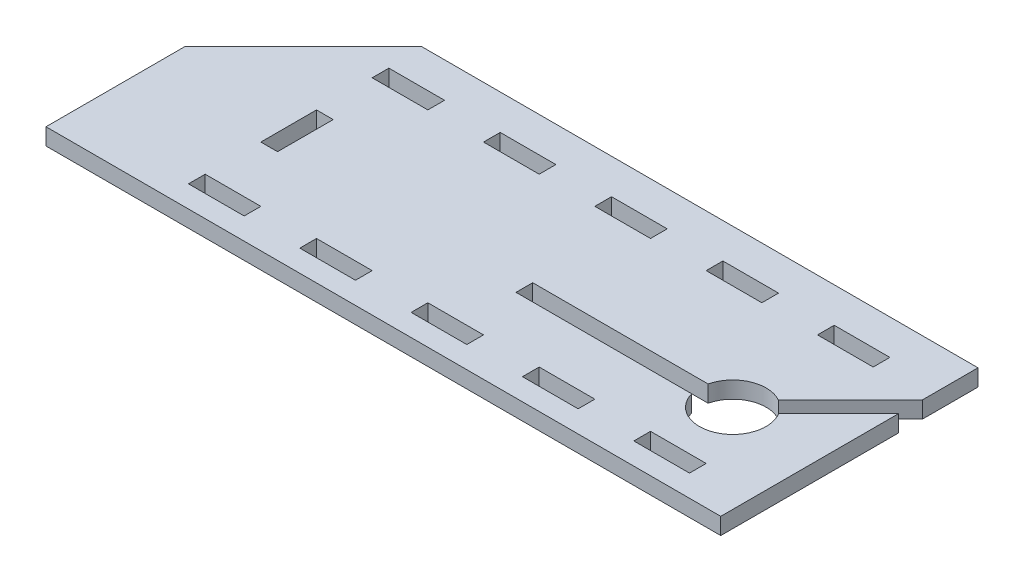
from build123d import *

# Parameters (mm, degrees)
ESQUISSE1_W        = 10
ESQUISSE1_H        = 3
ESQUISSE1_W_2      = 3
ESQUISSE1_H_2      = 10
BOSS_EXTRU_1_DEPTH = 3


with BuildPart() as part:
    # Esquisse1 → Boss.-Extru.1 (new body)
    with BuildSketch(Plane(origin=(0, 0, 0), x_dir=(1, 0, 0), z_dir=(0, 1, 0))):
        with BuildLine():
            Line((-48.586354215, -63.79082471), (72.626849221, -63.79082471))
            Line((72.626849221, -63.79082471), (72.626849221, -31.820261962))
            Line((72.626849221, -31.820261962), (61.846203207, -42.600907976))
            ThreePointArc((61.846203207, -42.600907976), (59.121902654, -51.239420877), (50.947990526, -47.336488751))
            Line((50.947990526, -47.336488751), (19.393465144, -47.336488751))
            Line((19.393465144, -47.336488751), (19.393465144, -44.336488751))
            Line((19.393465144, -44.336488751), (50.896342586, -44.336488751))
            ThreePointArc((50.896342586, -44.336488751), (54.339544234, -40.233556625), (59.688362254, -40.516108241))
            Line((59.688362254, -40.516108241), (72.626849221, -27.577621274))
            Line((72.626849221, -27.577621274), (72.626849221, -17.577621274))
            Line((72.626849221, -17.577621274), (-27.373150779, -17.577621274))
            Line((-27.373150779, -17.577621274), (-48.586354215, -38.79082471))
            Line((-48.586354215, -38.79082471), (-48.586354215, -63.79082471))
        make_face()
        with Locations((-1.907227595, -25.374770958)):
            Rectangle(ESQUISSE1_W, ESQUISSE1_H, mode=Mode.SUBTRACT)
        with Locations((-21.907227595, -25.374770958)):
            Rectangle(ESQUISSE1_W, ESQUISSE1_H, mode=Mode.SUBTRACT)
        with Locations((18.092772405, -25.374770958)):
            Rectangle(ESQUISSE1_W, ESQUISSE1_H, mode=Mode.SUBTRACT)
        with Locations((38.092772405, -25.374770958)):
            Rectangle(ESQUISSE1_W, ESQUISSE1_H, mode=Mode.SUBTRACT)
        with Locations((58.092772405, -25.374770958)):
            Rectangle(ESQUISSE1_W, ESQUISSE1_H, mode=Mode.SUBTRACT)
        with Locations((-21.907227595, -58.374770958)):
            Rectangle(ESQUISSE1_W, ESQUISSE1_H, mode=Mode.SUBTRACT)
        with Locations((-1.907227595, -58.374770958)):
            Rectangle(ESQUISSE1_W, ESQUISSE1_H, mode=Mode.SUBTRACT)
        with Locations((18.092772405, -58.374770958)):
            Rectangle(ESQUISSE1_W, ESQUISSE1_H, mode=Mode.SUBTRACT)
        with Locations((38.092772405, -58.374770958)):
            Rectangle(ESQUISSE1_W, ESQUISSE1_H, mode=Mode.SUBTRACT)
        with Locations((58.092772405, -58.374770958)):
            Rectangle(ESQUISSE1_W, ESQUISSE1_H, mode=Mode.SUBTRACT)
        with Locations((-25.407227595, -41.874770958)):
            Rectangle(ESQUISSE1_W_2, ESQUISSE1_H_2, mode=Mode.SUBTRACT)
    extrude(amount=BOSS_EXTRU_1_DEPTH)


solid = part.part
